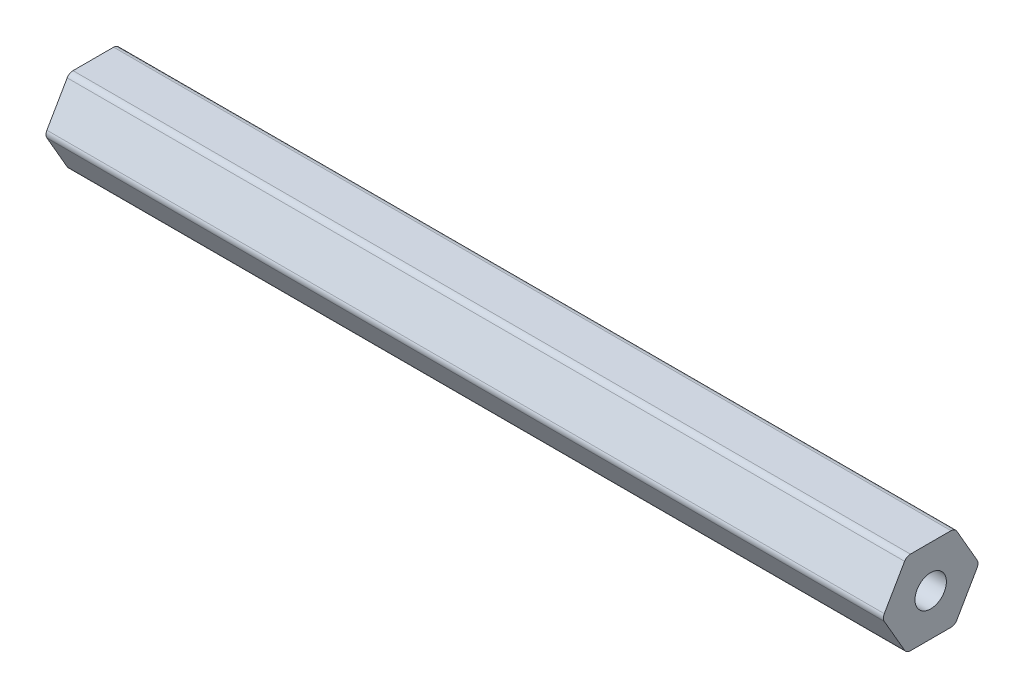
from build123d import *

# Parameters (mm, degrees)
SKETCH1_R           = 2.38125
BOSS_EXTRUDE1_DEPTH = 127


with BuildPart() as part:
    # Sketch1 → Boss-Extrude1 (new body)
    with BuildSketch(Plane(origin=(0, 0, 0), x_dir=(0, 0, -1), z_dir=(1, 0, 0))):
        with BuildLine():
            Line((7.039054482, 0.508), (3.959468146, 5.842))
            ThreePointArc((3.959468146, 5.842), (3.587586336, 6.21388181), (3.079586336, 6.35))
            Line((3.079586336, 6.35), (-3.079586336, 6.35))
            ThreePointArc((-3.079586336, 6.35), (-3.587586336, 6.21388181), (-3.959468146, 5.842))
            Line((-3.959468146, 5.842), (-7.039054482, 0.508))
            ThreePointArc((-7.039054482, 0.508), (-7.175172672, 0), (-7.039054482, -0.508))
            Line((-7.039054482, -0.508), (-3.959468146, -5.842))
            ThreePointArc((-3.959468146, -5.842), (-3.587586336, -6.21388181), (-3.079586336, -6.35))
            Line((-3.079586336, -6.35), (3.079586336, -6.35))
            ThreePointArc((3.079586336, -6.35), (3.587586336, -6.21388181), (3.959468146, -5.842))
            Line((3.959468146, -5.842), (7.039054482, -0.508))
            ThreePointArc((7.039054482, -0.508), (7.175172672, 0), (7.039054482, 0.508))
        make_face()
        Circle(SKETCH1_R, mode=Mode.SUBTRACT)
    extrude(amount=BOSS_EXTRUDE1_DEPTH)


solid = part.part
